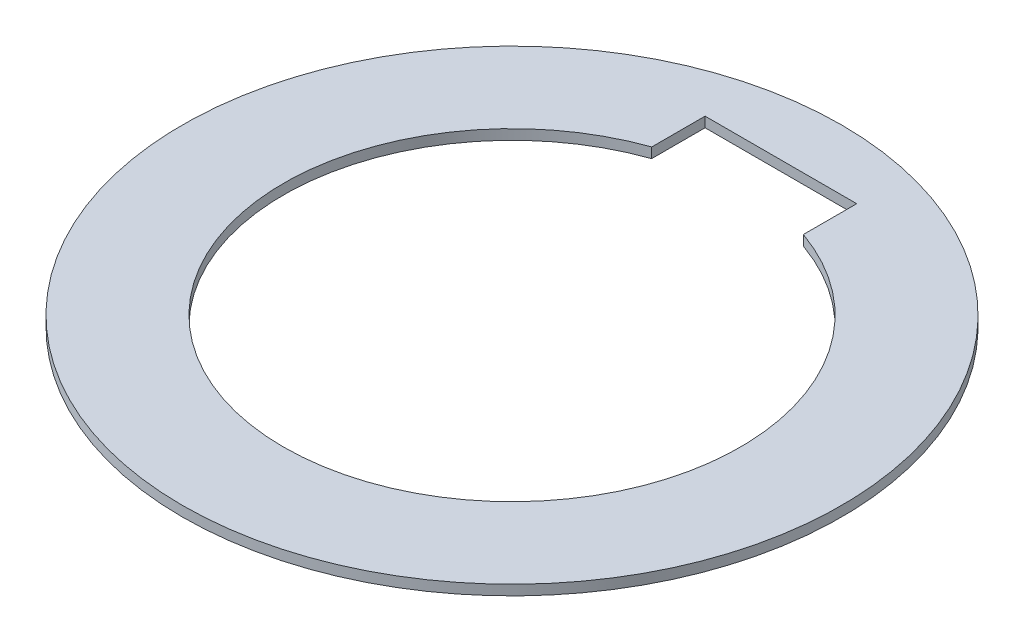
from build123d import *

# Parameters (mm, degrees)
SKETCH1_R      = 32.6
EXTRUDE1_DEPTH = 1


with BuildPart() as part:
    # Sketch1 → Extrude1 (new body)
    with BuildSketch(Plane(origin=(0, 0, 0), x_dir=(1, 0, 0), z_dir=(0, 1, 0))):
        Circle(SKETCH1_R)
        with BuildLine():
            Line((-7.5, 26.6), (-7.5, 21.319240137))
            ThreePointArc((-7.5, 21.319240137), (0, -22.6), (7.5, 21.319240137))
            Line((7.5, 21.319240137), (7.5, 26.6))
            Line((7.5, 26.6), (-7.5, 26.6))
        make_face(mode=Mode.SUBTRACT)
    extrude(amount=EXTRUDE1_DEPTH)


solid = part.part
